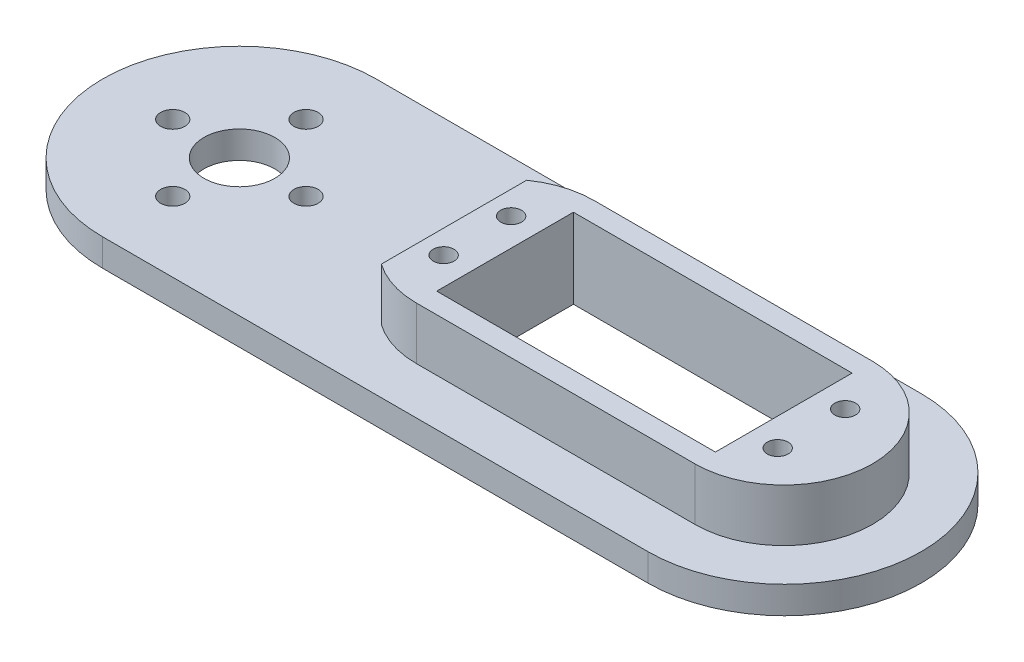
from build123d import *

# Parameters (mm, degrees)
SKETCH1_R               = 0.5
SKETCH1_R_2             = 1.375
BOSS_EXTRUDE1_DEPTH     = 2
SKETCH4_R               = 4.6270037
SKETCH4_R_2             = 2.6270037
BOSS_EXTRUDE3_DEPTH     = 2.5
CUT_EXTRUDE3_DEPTH      = 2.5
SKETCH6_R               = 20.066
SKETCH6_R_2             = 3.75
BOSS_EXTRUDE6_DEPTH     = 2.54
SKETCH7_R               = 1.778
CUT_EXTRUDE4_DEPTH      = 2.54
CIRPATTERN1_COUNT       = 4
BOSS_EXTRU_1_DEPTH      = 2.2225
BOSS_EXTRU_1_DEPTH_BACK = 2.54
ESQUISSE3_R             = 20.066
ESQUISSE3_R_2           = 1.778
ESQUISSE3_R_3           = 1.375
BOSS_EXTRU_2_DEPTH      = 2.2225
ENL_V_MAT_EXTRU_1_REACH = 104.179
ESQUISSE4_W             = 40.894
ESQUISSE4_H             = 20.066
ESQUISSE5_R             = 1.524
ENL_V_MAT_EXTRU_2_DEPTH = 103.178919246
ESQUISSE6_W             = 129.807809177
ESQUISSE6_H             = 84.506546368
ENL_V_MAT_EXTRU_3_DEPTH = 0.76
ESQUISSE7_R             = 5.2
ENL_V_MAT_EXTRU_4_DEPTH = 103.241877615
ESQUISSE8_R             = 1.524
ESQUISSE8_W             = 40.894
ESQUISSE8_H             = 20.066
BOSS_EXTRU_3_DEPTH      = 7.7
ESQUISSE9_W             = 7.452608866
ESQUISSE9_H             = 26.066
ENL_V_MAT_EXTRU_5_DEPTH = 7.7


with BuildPart() as part:
    # Sketch1 → Boss-Extrude1 (new body)
    with BuildSketch(Plane(origin=(0, 0, 0), x_dir=(1, 0, 0), z_dir=(0, 1, 0))):
        with BuildLine():
            Line((-4, 4), (-2.467435953, 13.402193757))
            ThreePointArc((-2.467435953, 13.402193757), (0, 15.5), (2.467435953, 13.402193757))
            Line((2.467435953, 13.402193757), (4, 4))
            Line((4, 4), (12.448472752, 2.459445505))
            ThreePointArc((12.448472752, 2.459445505), (14.5, 0), (12.448472752, -2.459445505))
            Line((12.448472752, -2.459445505), (4, -4))
            Line((4, -4), (2.467435953, -13.402193757))
            ThreePointArc((2.467435953, -13.402193757), (0, -15.5), (-2.467435953, -13.402193757))
            Line((-2.467435953, -13.402193757), (-4, -4))
            Line((-4, -4), (-12.448472752, -2.459445505))
            ThreePointArc((-12.448472752, -2.459445505), (-14.5, 0), (-12.448472752, 2.459445505))
            Line((-12.448472752, 2.459445505), (-4, 4))
        make_face()
        with Locations(Location((0, 12, 0), (0, 0, 270))):
            Circle(SKETCH1_R, mode=Mode.SUBTRACT)
        with Locations(Location((0, 9.5, 0), (0, 0, 270))):
            Circle(SKETCH1_R, mode=Mode.SUBTRACT)
        with Locations(Location((0, 7.5, 0), (0, 0, 270))):
            Circle(SKETCH1_R, mode=Mode.SUBTRACT)
        with Locations(Location((12, 0, 0), (0, 0, 270))):
            Circle(SKETCH1_R, mode=Mode.SUBTRACT)
        with Locations(Location((9.5, 0, 0), (0, 0, 270))):
            Circle(SKETCH1_R, mode=Mode.SUBTRACT)
        with Locations(Location((7.5, 0, 0), (0, 0, 270))):
            Circle(SKETCH1_R, mode=Mode.SUBTRACT)
        with Locations(Location((0, -12, 0), (0, 0, 270))):
            Circle(SKETCH1_R, mode=Mode.SUBTRACT)
        with Locations(Location((0, -9.5, 0), (0, 0, 270))):
            Circle(SKETCH1_R, mode=Mode.SUBTRACT)
        with Locations(Location((0, -7.5, 0), (0, 0, 270))):
            Circle(SKETCH1_R, mode=Mode.SUBTRACT)
        with Locations(Location((-12, 0, 0), (0, 0, 270))):
            Circle(SKETCH1_R, mode=Mode.SUBTRACT)
        with Locations(Location((-9.5, 0, 0), (0, 0, 270))):
            Circle(SKETCH1_R, mode=Mode.SUBTRACT)
        with Locations(Location((-7.5, 0, 0), (0, 0, 270))):
            Circle(SKETCH1_R, mode=Mode.SUBTRACT)
        with Locations(Location((0, 0, 0), (0, 0, 270))):
            Circle(SKETCH1_R_2, mode=Mode.SUBTRACT)
    extrude(amount=BOSS_EXTRUDE1_DEPTH)

    # Sketch4 → Boss-Extrude3 (add)
    with BuildSketch(Plane.XZ):
        with Locations(Location((0, 0, 0), (0, 0, 90))):
            Circle(SKETCH4_R)
        with Locations(Location((0, 0, 0), (0, 0, 270))):
            Circle(SKETCH4_R_2, mode=Mode.SUBTRACT)
    extrude(amount=BOSS_EXTRUDE3_DEPTH)

    # Sketch5 → Cut-Extrude3 (cut)
    with BuildSketch(Plane.XZ.offset(2.5)):
        with BuildLine():
            Line((0.282820055, 2.611735296), (0, 3.101594))
            Line((0, 3.101594), (-0.282820055, 2.611735296))
            ThreePointArc((-0.282820055, 2.611735296), (-0.410953918, 2.594660925), (-0.538092735, 2.571304075))
            Line((-0.538092735, 2.571304075), (-0.958445256, 2.949791185))
            Line((-0.958445256, 2.949791185), (-1.076048447, 2.396511669))
            ThreePointArc((-1.076048447, 2.396511669), (-1.192634723, 2.340677436), (-1.306333259, 2.279175696))
            Line((-1.306333259, 2.279175696), (-1.823071212, 2.509242256))
            Line((-1.823071212, 2.509242256), (-1.76394572, 1.946700782))
            ThreePointArc((-1.76394572, 1.946700782), (-1.85757213, 1.85757213), (-1.946700782, 1.76394572))
            Line((-1.946700782, 1.76394572), (-2.509242256, 1.823071212))
            Line((-2.509242256, 1.823071212), (-2.279175696, 1.306333259))
            ThreePointArc((-2.279175696, 1.306333259), (-2.340677436, 1.192634723), (-2.396511669, 1.076048447))
            Line((-2.396511669, 1.076048447), (-2.949791185, 0.958445256))
            Line((-2.949791185, 0.958445256), (-2.571304075, 0.538092735))
            ThreePointArc((-2.571304075, 0.538092735), (-2.594660925, 0.410953918), (-2.611735296, 0.282820055))
            Line((-2.611735296, 0.282820055), (-3.101594, 0))
            Line((-3.101594, 0), (-2.611735296, -0.282820055))
            ThreePointArc((-2.611735296, -0.282820055), (-2.594660925, -0.410953918), (-2.571304075, -0.538092735))
            Line((-2.571304075, -0.538092735), (-2.949791185, -0.958445256))
            Line((-2.949791185, -0.958445256), (-2.396511669, -1.076048447))
            ThreePointArc((-2.396511669, -1.076048447), (-2.340677436, -1.192634723), (-2.279175696, -1.306333259))
            Line((-2.279175696, -1.306333259), (-2.509242256, -1.823071212))
            Line((-2.509242256, -1.823071212), (-1.946700782, -1.76394572))
            ThreePointArc((-1.946700782, -1.76394572), (-1.85757213, -1.85757213), (-1.76394572, -1.946700782))
            Line((-1.76394572, -1.946700782), (-1.823071212, -2.509242256))
            Line((-1.823071212, -2.509242256), (-1.306333259, -2.279175696))
            ThreePointArc((-1.306333259, -2.279175696), (-1.192634723, -2.340677436), (-1.076048447, -2.396511669))
            Line((-1.076048447, -2.396511669), (-0.958445256, -2.949791185))
            Line((-0.958445256, -2.949791185), (-0.538092735, -2.571304075))
            ThreePointArc((-0.538092735, -2.571304075), (-0.410953918, -2.594660925), (-0.282820055, -2.611735296))
            Line((-0.282820055, -2.611735296), (0, -3.101594))
            Line((0, -3.101594), (0.282820055, -2.611735296))
            ThreePointArc((0.282820055, -2.611735296), (0.410953918, -2.594660925), (0.538092735, -2.571304075))
            Line((0.538092735, -2.571304075), (0.958445256, -2.949791185))
            Line((0.958445256, -2.949791185), (1.076048447, -2.396511669))
            ThreePointArc((1.076048447, -2.396511669), (1.192634723, -2.340677436), (1.306333259, -2.279175696))
            Line((1.306333259, -2.279175696), (1.823071212, -2.509242256))
            Line((1.823071212, -2.509242256), (1.76394572, -1.946700782))
            ThreePointArc((1.76394572, -1.946700782), (1.85757213, -1.85757213), (1.946700782, -1.76394572))
            Line((1.946700782, -1.76394572), (2.509242256, -1.823071212))
            Line((2.509242256, -1.823071212), (2.279175696, -1.306333259))
            ThreePointArc((2.279175696, -1.306333259), (2.340677436, -1.192634723), (2.396511669, -1.076048447))
            Line((2.396511669, -1.076048447), (2.949791185, -0.958445256))
            Line((2.949791185, -0.958445256), (2.571304075, -0.538092735))
            ThreePointArc((2.571304075, -0.538092735), (2.594660925, -0.410953918), (2.611735296, -0.282820055))
            Line((2.611735296, -0.282820055), (3.101594, 0))
            Line((3.101594, 0), (2.611735296, 0.282820055))
            ThreePointArc((2.611735296, 0.282820055), (2.594660925, 0.410953918), (2.571304075, 0.538092735))
            Line((2.571304075, 0.538092735), (2.949791185, 0.958445256))
            Line((2.949791185, 0.958445256), (2.396511669, 1.076048447))
            ThreePointArc((2.396511669, 1.076048447), (2.340677436, 1.192634723), (2.279175696, 1.306333259))
            Line((2.279175696, 1.306333259), (2.509242256, 1.823071212))
            Line((2.509242256, 1.823071212), (1.946700782, 1.76394572))
            ThreePointArc((1.946700782, 1.76394572), (1.85757213, 1.85757213), (1.76394572, 1.946700782))
            Line((1.76394572, 1.946700782), (1.823071212, 2.509242256))
            Line((1.823071212, 2.509242256), (1.306333259, 2.279175696))
            ThreePointArc((1.306333259, 2.279175696), (1.192634723, 2.340677436), (1.076048447, 2.396511669))
            Line((1.076048447, 2.396511669), (0.958445256, 2.949791185))
            Line((0.958445256, 2.949791185), (0.538092735, 2.571304075))
            ThreePointArc((0.538092735, 2.571304075), (0.410953918, 2.594660925), (0.282820055, 2.611735296))
        make_face()
    extrude(amount=-CUT_EXTRUDE3_DEPTH, mode=Mode.SUBTRACT)

    # Sketch6 → Boss-Extrude6 (add)
    with BuildSketch(Plane(origin=(0, 2, 0), x_dir=(1, 0, 0), z_dir=(0, 1, 0))):
        with Locations(Location((0, 0, 0), (0, 0, 270))):
            Circle(SKETCH6_R)
        Circle(SKETCH6_R_2, mode=Mode.SUBTRACT)
    extrude(amount=-BOSS_EXTRUDE6_DEPTH)

    # Sketch7 → Cut-Extrude4 (cut)
    with BuildSketch(Plane(origin=(0, 2, 0), x_dir=(1, 0, 0), z_dir=(0, 1, 0))):
        with Locations(Location((0, 9.779, 0), (0, 0, 270))):
            Circle(SKETCH7_R)
    cut_extrude4 = extrude(amount=-CUT_EXTRUDE4_DEPTH, mode=Mode.SUBTRACT)

    # CirPattern1: Cut-Extrude4 ×4 about axis
    cirpattern1_axis = Axis((0, 0, 0), (0, 1, 0))
    for i in range(1, CIRPATTERN1_COUNT):
        add(cut_extrude4.rotate(cirpattern1_axis, i * 360 / CIRPATTERN1_COUNT), mode=Mode.SUBTRACT)

    # Esquisse1 → Boss.-Extru.1 (add, two sides)
    with BuildSketch(Plane(origin=(0, 2, 0), x_dir=(1, 0, 0), z_dir=(0, 1, 0))) as boss_extru_1_sk:
        with BuildLine():
            Line((0, 20.066), (80.01, 20.066))
            ThreePointArc((80.01, 20.066), (100.076, 0), (80.01, -20.066))
            Line((80.01, -20.066), (0, -20.066))
            ThreePointArc((0, -20.066), (20.066, 0), (0, 20.066))
        make_face()
    extrude(amount=BOSS_EXTRU_1_DEPTH)
    extrude(boss_extru_1_sk.sketch, amount=-BOSS_EXTRU_1_DEPTH_BACK)

    # Esquisse3 → Boss.-Extru.2 (add)
    with BuildSketch(Plane(origin=(0, 2, 0), x_dir=(1, 0, 0), z_dir=(0, 1, 0))):
        Circle(ESQUISSE3_R)
        with Locations(Location((9.779, 0, 0), (0, 0, 270))):
            Circle(ESQUISSE3_R_2, mode=Mode.SUBTRACT)
        with Locations(Location((0, 9.779, 0), (0, 0, 270))):
            Circle(ESQUISSE3_R_2, mode=Mode.SUBTRACT)
        with Locations(Location((-9.779, 0, 0), (0, 0, 270))):
            Circle(ESQUISSE3_R_2, mode=Mode.SUBTRACT)
        with Locations(Location((0, -9.779, 0), (0, 0, 270))):
            Circle(ESQUISSE3_R_2, mode=Mode.SUBTRACT)
        with Locations(Location((0, 0, 0), (0, 0, 270))):
            Circle(ESQUISSE3_R_3, mode=Mode.SUBTRACT)
    extrude(amount=BOSS_EXTRU_2_DEPTH)

    # Esquisse4 → Enlèv. mat.-Extru.1 (cut, up to next)
    with BuildSketch(Plane.XZ.offset(0.54), mode=Mode.PRIVATE) as enl_v_mat_extru_1_sk1:
        with Locations((59.563, 0.127)):
            Rectangle(ESQUISSE4_W, ESQUISSE4_H)
    enl_v_mat_extru_1_tool1 = extrude(enl_v_mat_extru_1_sk1.sketch, amount=-ENL_V_MAT_EXTRU_1_REACH, mode=Mode.PRIVATE) & part.part
    add(enl_v_mat_extru_1_tool1.solids().sort_by_distance((59.563, -0.54, 0.127))[0], mode=Mode.SUBTRACT)

    # Esquisse5 → Enlèv. mat.-Extru.2 (cut, through all)
    with BuildSketch(Plane(origin=(0, -0.54, 0), x_dir=(-1, 0, 0), z_dir=(0, -1, 0))):
        with Locations(Location((-35.052, -5.08, 0), (0, 0, 90))):
            Circle(ESQUISSE5_R)
        with Locations(Location((-35.052, 4.826, 0), (0, 0, 90))):
            Circle(ESQUISSE5_R)
        with Locations(Location((-84.074, -5.08, 0), (0, 0, 90))):
            Circle(ESQUISSE5_R)
        with Locations(Location((-84.074, 4.826, 0), (0, 0, 90))):
            Circle(ESQUISSE5_R)
    extrude(amount=-ENL_V_MAT_EXTRU_2_DEPTH, mode=Mode.SUBTRACT)

    # Esquisse6 → Enlèv. mat.-Extru.3 (cut)
    with BuildSketch(Plane(origin=(0, 4.2225, 0), x_dir=(1, 0, 0), z_dir=(0, 1, 0))):
        with Locations((40.86254749, 2.128524174)):
            Rectangle(ESQUISSE6_W, ESQUISSE6_H)
    extrude(amount=-ENL_V_MAT_EXTRU_3_DEPTH, mode=Mode.SUBTRACT)

    # Esquisse7 → Enlèv. mat.-Extru.4 (cut, through all)
    with BuildSketch(Plane(origin=(0, -2.5, 0), x_dir=(-1, 0, 0), z_dir=(0, -1, 0))):
        with Locations(Location((0, 0, 0), (0, 0, 90))):
            Circle(ESQUISSE7_R)
    extrude(amount=-ENL_V_MAT_EXTRU_4_DEPTH, mode=Mode.SUBTRACT)

    # Esquisse8 → Boss.-Extru.3 (add)
    with BuildSketch(Plane(origin=(0, 3.4625, 0), x_dir=(1, 0, 0), z_dir=(0, 1, 0))):
        with BuildLine():
            Line((80.01, -13.16), (39.116, -13.16))
            ThreePointArc((39.116, -13.16), (26.083, -0.127), (39.116, 12.906))
            Line((39.116, 12.906), (80.01, 12.906))
            ThreePointArc((80.01, 12.906), (93.043, -0.127), (80.01, -13.16))
        make_face()
        with Locations(Location((84.074, -5.08, 0), (0, 0, 90))):
            Circle(ESQUISSE8_R, mode=Mode.SUBTRACT)
        with Locations(Location((84.074, 4.826, 0), (0, 0, 90))):
            Circle(ESQUISSE8_R, mode=Mode.SUBTRACT)
        with Locations(Location((35.052, -5.08, 0), (0, 0, 90))):
            Circle(ESQUISSE8_R, mode=Mode.SUBTRACT)
        with Locations(Location((35.052, 4.826, 0), (0, 0, 90))):
            Circle(ESQUISSE8_R, mode=Mode.SUBTRACT)
        with Locations((59.563, -0.127)):
            Rectangle(ESQUISSE8_W, ESQUISSE8_H, mode=Mode.SUBTRACT)
    extrude(amount=BOSS_EXTRU_3_DEPTH)

    # Esquisse9 → Enlèv. mat.-Extru.5 (cut)
    with BuildSketch(Plane(origin=(0, 11.1625, 0), x_dir=(1, 0, 0), z_dir=(0, 1, 0))):
        with Locations((27.889695567, -0.127)):
            Rectangle(ESQUISSE9_W, ESQUISSE9_H)
    extrude(amount=-ENL_V_MAT_EXTRU_5_DEPTH, mode=Mode.SUBTRACT)


solid = part.part
